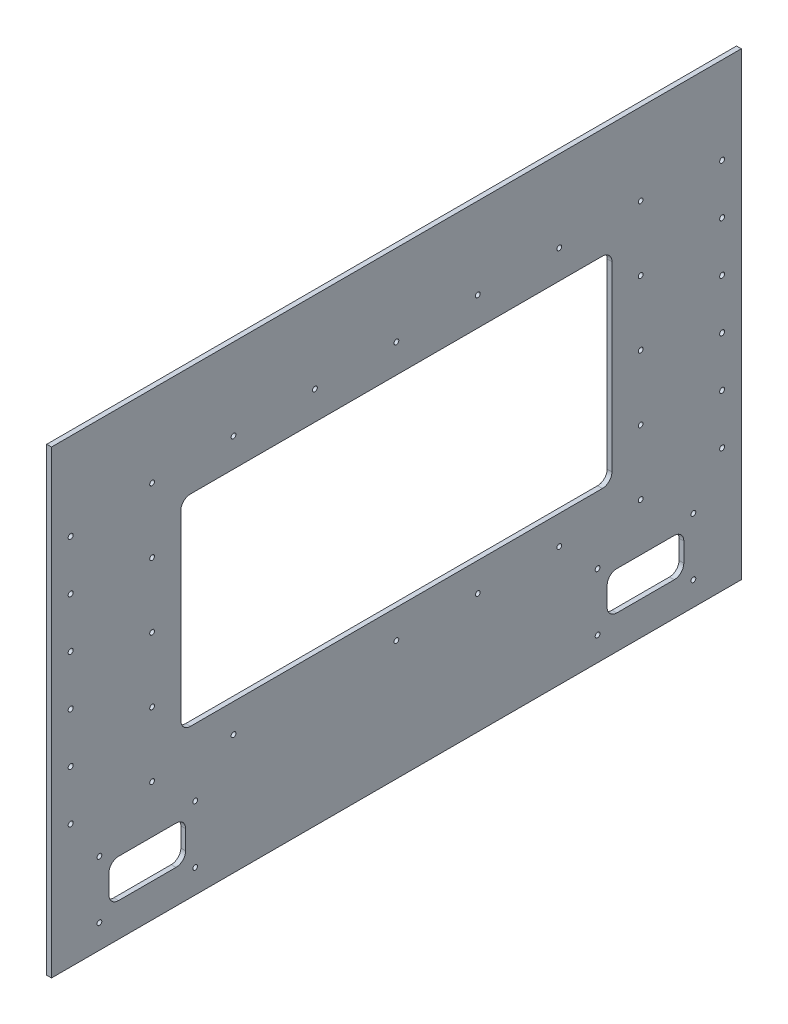
from build123d import *

# Parameters (mm, degrees)
SKETCH1_W           = 914.4
SKETCH1_H           = 609.6
BOSS_EXTRUDE1_DEPTH = 6.35
SKETCH2_W           = 571.5
SKETCH2_H           = 266.7
CUT_EXTRUDE1_DEPTH  = 7.35
SKETCH3_W           = 101.6
SKETCH3_H           = 50.8
CUT_EXTRUDE2_DEPTH  = 7.35
FILLET1_R           = 12.7
SKETCH4_R           = 3.175
CUT_EXTRUDE3_DEPTH  = 7.35
SKETCH6_R           = 3.302
CUT_EXTRUDE5_DEPTH  = 6.35


with BuildPart() as part:
    # Sketch1 → Boss-Extrude1 (new body)
    with BuildSketch(Plane.ZY.offset(304.8)):
        with Locations((0, 304.8)):
            Rectangle(SKETCH1_W, SKETCH1_H)
    extrude(amount=BOSS_EXTRUDE1_DEPTH)

    # Sketch2 → Cut-Extrude1 (cut, through all)
    with BuildSketch(Plane.ZY.offset(311.15)):
        with Locations((0, 330.2)):
            Rectangle(SKETCH2_W, SKETCH2_H)
    extrude(amount=-CUT_EXTRUDE1_DEPTH, mode=Mode.SUBTRACT)

    # Sketch3 → Cut-Extrude2 (cut, through all)
    with BuildSketch(Plane.ZY.offset(311.15)):
        with Locations((-330.2, 69.85)):
            Rectangle(SKETCH3_W, SKETCH3_H)
        with Locations((330.2, 69.85)):
            Rectangle(SKETCH3_W, SKETCH3_H)
    extrude(amount=-CUT_EXTRUDE2_DEPTH, mode=Mode.SUBTRACT)

    # Fillet1
    fillet1_edges = [part.edges().sort_by_distance(p)[0] for p in [
        (-307.975, 196.85, -285.75),
        (-307.975, 463.55, -285.75),
        (-307.975, 463.55, 285.75),
        (-307.975, 196.85, 285.75),
        (-307.975, 44.45, -381),
        (-307.975, 95.25, -381),
        (-307.975, 95.25, -279.4),
        (-307.975, 44.45, -279.4),
        (-307.975, 95.25, 279.4),
        (-307.975, 95.25, 381),
        (-307.975, 44.45, 381),
        (-307.975, 44.45, 279.4),
    ]]
    fillet(fillet1_edges, radius=FILLET1_R)

    # Sketch4 → Cut-Extrude3 (cut, through all)
    with BuildSketch(Plane.ZY.offset(311.15)):
        with Locations((323.85, 244.475)):
            Circle(SKETCH4_R)
        with Locations((-323.85, 244.475)):
            Circle(SKETCH4_R)
        with Locations((-107.95, 158.75)):
            Circle(SKETCH4_R)
        with Locations((0, 158.75)):
            Circle(SKETCH4_R)
        with Locations((215.9, 158.75)):
            Circle(SKETCH4_R)
        with Locations((323.85, 158.75)):
            Circle(SKETCH4_R)
        with Locations((-323.85, 158.75)):
            Circle(SKETCH4_R)
        with Locations((-215.9, 158.75)):
            Circle(SKETCH4_R)
        with Locations((266.7, 31.75)):
            Circle(SKETCH4_R)
        with Locations((393.7, 31.75)):
            Circle(SKETCH4_R)
        with Locations((266.7, 107.95)):
            Circle(SKETCH4_R)
        with Locations((393.7, 107.95)):
            Circle(SKETCH4_R)
        with Locations((-266.7, 31.75)):
            Circle(SKETCH4_R)
        with Locations((-393.7, 31.75)):
            Circle(SKETCH4_R)
        with Locations((-393.7, 107.95)):
            Circle(SKETCH4_R)
        with Locations((-266.7, 107.95)):
            Circle(SKETCH4_R)
        with Locations((323.85, 330.2)):
            Circle(SKETCH4_R)
        with Locations((323.85, 415.925)):
            Circle(SKETCH4_R)
        with Locations((323.85, 501.65)):
            Circle(SKETCH4_R)
        with Locations((215.9, 501.65)):
            Circle(SKETCH4_R)
        with Locations((107.95, 501.65)):
            Circle(SKETCH4_R)
        with Locations((0, 501.65)):
            Circle(SKETCH4_R)
        with Locations((-107.95, 501.65)):
            Circle(SKETCH4_R)
        with Locations((-215.9, 501.65)):
            Circle(SKETCH4_R)
        with Locations((-323.85, 501.65)):
            Circle(SKETCH4_R)
        with Locations((-323.85, 415.925)):
            Circle(SKETCH4_R)
        with Locations((-323.85, 330.2)):
            Circle(SKETCH4_R)
    extrude(amount=-CUT_EXTRUDE3_DEPTH, mode=Mode.SUBTRACT)

    # Sketch6 → Cut-Extrude5 (cut)
    with BuildSketch(Plane.ZY.offset(311.15)):
        with Locations((431.8, 164.084)):
            Circle(SKETCH6_R)
        with Locations((431.8, 230.124)):
            Circle(SKETCH6_R)
        with Locations((431.8, 296.164)):
            Circle(SKETCH6_R)
        with Locations((431.8, 362.204)):
            Circle(SKETCH6_R)
        with Locations((431.8, 428.244)):
            Circle(SKETCH6_R)
        with Locations((431.8, 494.284)):
            Circle(SKETCH6_R)
        with Locations((-431.8, 230.124)):
            Circle(SKETCH6_R)
        with Locations((-431.8, 296.164)):
            Circle(SKETCH6_R)
        with Locations((-431.8, 362.204)):
            Circle(SKETCH6_R)
        with Locations((-431.8, 428.244)):
            Circle(SKETCH6_R)
        with Locations((-431.8, 494.284)):
            Circle(SKETCH6_R)
        with Locations((-431.8, 164.084)):
            Circle(SKETCH6_R)
    extrude(amount=-CUT_EXTRUDE5_DEPTH, mode=Mode.SUBTRACT)


solid = part.part
